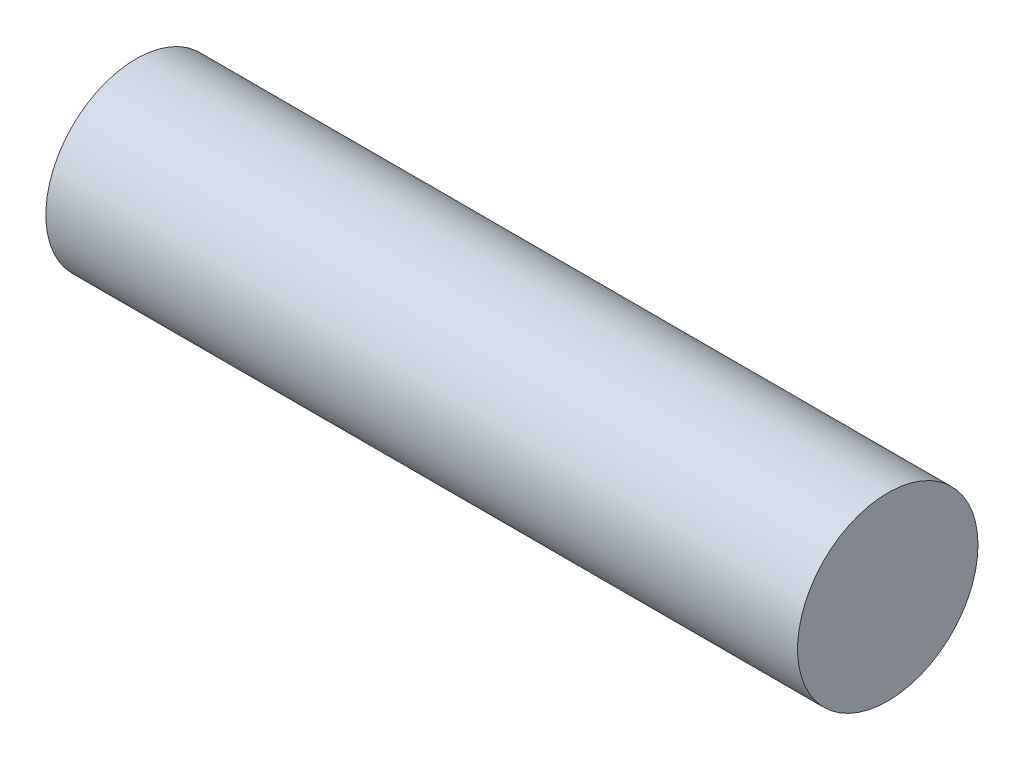
from build123d import *

# Parameters (mm, degrees)
CROQUIS1_R              = 3
SALIENTE_EXTRUIR1_DEPTH = 25


with BuildPart() as part:
    # Croquis1 → Saliente-Extruir1 (new body)
    with BuildSketch(Plane(origin=(0, 0, 0), x_dir=(0, 0, -1), z_dir=(1, 0, 0))):
        Circle(CROQUIS1_R)
    extrude(amount=SALIENTE_EXTRUIR1_DEPTH)


solid = part.part
